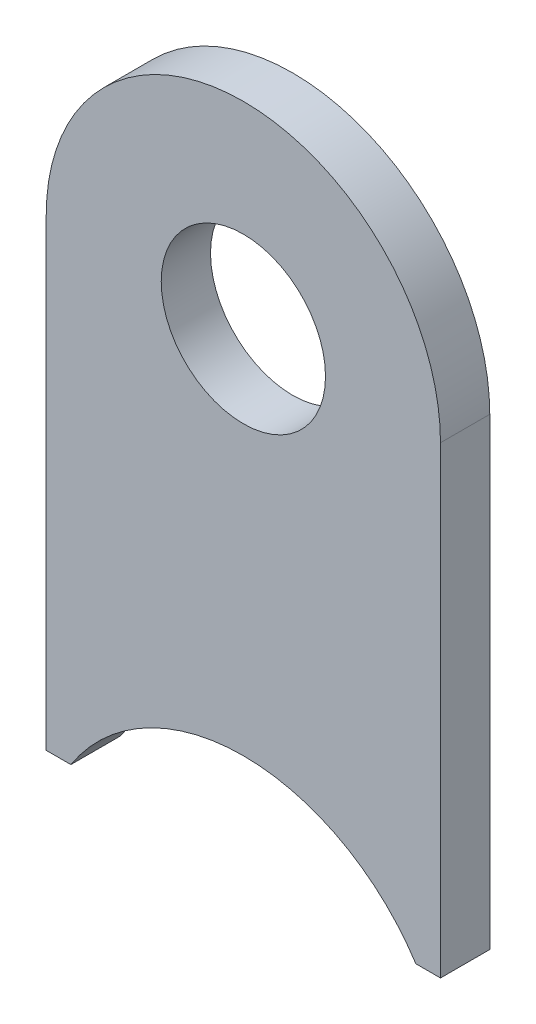
from build123d import *

# Parameters (mm, degrees)
SZKIC1_R                    = 5
DODANIE_WYCI_GNI_CIE1_DEPTH = 3


with BuildPart() as part:
    # Szkic1 → Dodanie-wyciągnięcie1 (new body)
    with BuildSketch(Plane(origin=(0, 0, -1.5), x_dir=(-1, 0, 0), z_dir=(0, 0, -1))):
        with BuildLine():
            Line((-12, 0), (-12, -28.217670017))
            Line((-12, -28.217670017), (-10.5, -28.217670017))
            ThreePointArc((-10.5, -28.217670017), (0, -22.5), (10.5, -28.217670017))
            Line((10.5, -28.217670017), (12, -28.217670017))
            Line((12, -28.217670017), (12, 0))
            ThreePointArc((12, 0), (0, 12), (-12, 0))
        make_face()
        Circle(SZKIC1_R, mode=Mode.SUBTRACT)
    extrude(amount=-DODANIE_WYCI_GNI_CIE1_DEPTH)


solid = part.part
